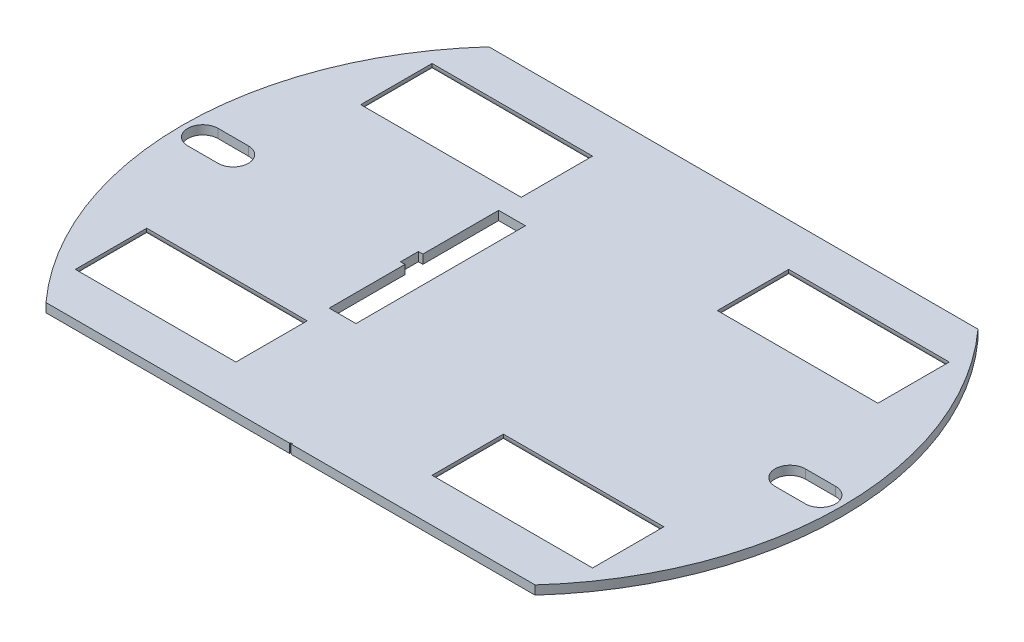
from build123d import *

# Parameters (mm, degrees)
BOSS_EXTRUDE1_DEPTH     = 2
SKETCH2_W               = 3.5
SKETCH2_H               = 2
CUT_EXTRUDE1_DEPTH      = 22
BOSS_EXTRUDE2_DEPTH     = 7
BOSS_EXTRUDE3_DEPTH     = 6
SKETCH5_R               = 2.25
CUT_EXTRUDE3_DEPTH      = 37
CUT_EXTRUDE3_DEPTH_BACK = 37
FILLET1_R               = 3
FILLET2_R               = 0.5
CUT_EXTRUDE4_DEPTH      = 37
FILLET3_R               = 0.5
FILLET4_R               = 0.5
CUT_EXTRUDE5_DEPTH      = 10
FILLET8_R               = 1
SKETCH8_W               = 0.1
SKETCH8_H               = 1
CUT_EXTRUDE6_DEPTH      = 0.1
SKETCH11_R              = 50.237983701
CUT_EXTRUDE8_DEPTH      = 11
CUT_EXTRUDE8_DEPTH_BACK = 1


with BuildPart() as part:
    # Sketch1 → Boss-Extrude1 (new body)
    with BuildSketch(Plane(origin=(0, 0, 0), x_dir=(1, 0, 0), z_dir=(0, 1, 0))):
        with BuildLine():
            Line((-27.424590139, -24.837307739), (27.424590139, -24.837307739))
            ThreePointArc((27.424590139, -24.837307739), (37, 0), (27.424590139, 24.837307739))
            Line((27.424590139, 24.837307739), (-27.424590139, 24.837307739))
            ThreePointArc((-27.424590139, 24.837307739), (-37, 0), (-27.424590139, -24.837307739))
        make_face()
    extrude(amount=BOSS_EXTRUDE1_DEPTH)

    # Sketch2 → Cut-Extrude1 (cut)
    with BuildSketch(Plane.XZ):
        Polygon((-8, 0), (-8, 9.5), (-11, 9.5), (-11, -9.5), (-8, -9.5), align=None)
        with Locations((-9.75, 0)):
            Rectangle(SKETCH2_W, SKETCH2_H)
    extrude(amount=-CUT_EXTRUDE1_DEPTH, mode=Mode.SUBTRACT)

    # Sketch3 → Boss-Extrude2 (add)
    with BuildSketch(Plane(origin=(0, 2, 0), x_dir=(1, 0, 0), z_dir=(0, 1, 0))):
        Polygon((2.9, 11.6), (2.9, 10.1), (19, 10.1), (20.5, 10.1), (20.5, 11.6), align=None)
        Polygon((20.5, 10.1), (19, 10.1), (19, -10.1), (19, -11.6), (20.5, -11.6), align=None)
        Polygon((19, -11.6), (19, -10.1), (-14.6, -10.1), (-16.1, -10.1), (-16.1, -11.6), align=None)
        Polygon((-14.6, 10.1), (2.9, 10.1), (2.9, 11.6), (-16.1, 11.6), (-16.1, 10.1), align=None)
    extrude(amount=BOSS_EXTRUDE2_DEPTH)

    # Sketch4 → Boss-Extrude3 (add)
    with BuildSketch(Plane.XZ):
        Polygon((-8, 0), (-8.02303658, 9.318964787), (-3, 9.318964787), (-3, -9.5), (-8, -9.5), align=None)
    extrude(amount=BOSS_EXTRUDE3_DEPTH)

    # Sketch5 → Cut-Extrude3 (cut, two sides)
    with BuildSketch(Plane.ZY.offset(8)) as cut_extrude3_sk:
        with Locations((-5.031035213, -2.35)):
            Circle(SKETCH5_R)
        with Locations((5.031035213, -2.35)):
            Circle(SKETCH5_R)
    extrude(amount=CUT_EXTRUDE3_DEPTH, mode=Mode.SUBTRACT)
    extrude(cut_extrude3_sk.sketch, amount=-CUT_EXTRUDE3_DEPTH_BACK, mode=Mode.SUBTRACT)

    # Fillet1
    fillet1_edges = [part.edges().sort_by_distance(p)[0] for p in [
        (-5.5, -6, -9.5),
        (-5.51151829, -6, 9.318964787),
    ]]
    fillet(fillet1_edges, radius=FILLET1_R)

    # Fillet2
    fillet2_edges = [part.edges().sort_by_distance(p)[0] for p in [
        (-37, 2, 0),
        (37, 2, 0),
    ]]
    fillet(fillet2_edges, radius=FILLET2_R)

    # Sketch6 → Cut-Extrude4 (cut)
    with BuildSketch(Plane.XZ):
        with BuildLine():
            Line((-34.696885188, 1.668964787), (-31.296885188, 1.668964787))
            ThreePointArc((-31.296885188, 1.668964787), (-29.596885188, -0.031035213), (-31.296885188, -1.731035213))
            Line((-31.296885188, -1.731035213), (-34.696885188, -1.731035213))
            ThreePointArc((-34.696885188, -1.731035213), (-36.396885188, -0.031035213), (-34.696885188, 1.668964787))
        make_face()
        with BuildLine():
            Line((31.302827177, 1.806746588), (34.702827177, 1.806746588))
            ThreePointArc((34.702827177, 1.806746588), (36.402827177, 0.106746588), (34.702827177, -1.593253412))
            Line((34.702827177, -1.593253412), (31.302827177, -1.593253412))
            ThreePointArc((31.302827177, -1.593253412), (29.602827177, 0.106746588), (31.302827177, 1.806746588))
        make_face()
    extrude(amount=-CUT_EXTRUDE4_DEPTH, mode=Mode.SUBTRACT)

    # Fillet3
    fillet3_edges = [part.edges().sort_by_distance(p)[0] for p in [
        (20.5, 9, 0),
        (2.2, 9, -11.6),
        (2.2, 9, 11.6),
        (1.45, 9, -10.1),
        (19, 9, 0),
        (1.45, 9, 10.1),
    ]]
    fillet(fillet3_edges, radius=FILLET3_R)

    # Fillet4
    fillet4_edges = [part.edges().sort_by_distance(p)[0] for p in [
        (-16.1, 9, -10.85),
        (-16.1, 9, 10.85),
        (-16.1, 5.25, -10.1),
        (-16.1, 5.25, -11.6),
        (-16.1, 8.853553391, -11.453553391),
        (-16.1, 8.853553391, -10.246446609),
        (-16.1, 5.25, 11.6),
        (-16.1, 5.25, 10.1),
        (-16.1, 8.853553391, 10.246446609),
        (-16.1, 8.853553391, 11.453553391),
    ]]
    fillet(fillet4_edges, radius=FILLET4_R)

    # Sketch7 → Cut-Extrude5 (cut)
    with BuildSketch(Plane.XZ):
        Polygon((-19.996885188, 19.968964787), (-10.996885188, 19.968964787), (-10.996885188, 11.968964787), (-28.996885188, 11.968964787), (-28.996885188, 19.968964787), align=None)
        Polygon((11.003114812, 11.968964787), (20.003114812, 11.968964787), (20.003114812, 14.968964787), (20.003114812, 19.968964787), (11.003114812, 19.968964787), align=None)
        Polygon((20.003114812, 14.968964787), (20.003114812, 11.968964787), (29.003114812, 11.968964787), (29.003114812, 19.968964787), (20.003114812, 19.968964787), align=None)
        Polygon((-28.996885188, -12.031035213), (-28.996885188, -20.031035213), (-19.996885188, -20.031035213), (-10.996885188, -20.031035213), (-10.996885188, -12.031035213), align=None)
        Polygon((20.003114812, -20.031035213), (11.003114812, -20.031035213), (11.003114812, -12.031035213), (29.003114812, -12.031035213), (29.003114812, -20.031035213), align=None)
    extrude(amount=-CUT_EXTRUDE5_DEPTH, mode=Mode.SUBTRACT)

    # Fillet8
    fillet8_edges = [part.edges().sort_by_distance(p)[0] for p in [
        (11.003114812, 0, 15.968964787),
        (20.003114812, 0, 11.968964787),
        (29.003114812, 0, 15.968964787),
        (20.003114812, 0, 19.968964787),
        (-28.996885188, 0, -16.031035213),
        (-19.996885188, 0, -20.031035213),
        (-10.996885188, 0, -16.031035213),
        (-19.996885188, 0, -12.031035213),
        (20.003114812, 0, -20.031035213),
        (11.003114812, 0, -16.031035213),
        (20.003114812, 0, -12.031035213),
        (29.003114812, 0, -16.031035213),
        (-19.996885188, 0, 19.968964787),
        (-10.996885188, 0, 15.968964787),
        (-19.996885188, 0, 11.968964787),
        (-28.996885188, 0, 15.968964787),
    ]]
    fillet(fillet8_edges, radius=FILLET8_R)

    # Sketch8 → Cut-Extrude6 (cut)
    with BuildSketch(Plane.XY.offset(24.837307739)):
        with Locations((-0.05, 0.5)):
            Rectangle(SKETCH8_W, SKETCH8_H)
        with Locations((0.05, 0.5)):
            Rectangle(SKETCH8_W, SKETCH8_H)
    extrude(amount=-CUT_EXTRUDE6_DEPTH, mode=Mode.SUBTRACT)

    # Sketch11 → Cut-Extrude8 (cut, two sides)
    with BuildSketch(Plane(origin=(0, 2, 0), x_dir=(1, 0, 0), z_dir=(0, 1, 0))) as cut_extrude8_sk:
        Circle(SKETCH11_R)
    extrude(amount=CUT_EXTRUDE8_DEPTH, mode=Mode.SUBTRACT)
    extrude(cut_extrude8_sk.sketch, amount=-CUT_EXTRUDE8_DEPTH_BACK, mode=Mode.SUBTRACT)


solid = part.part
